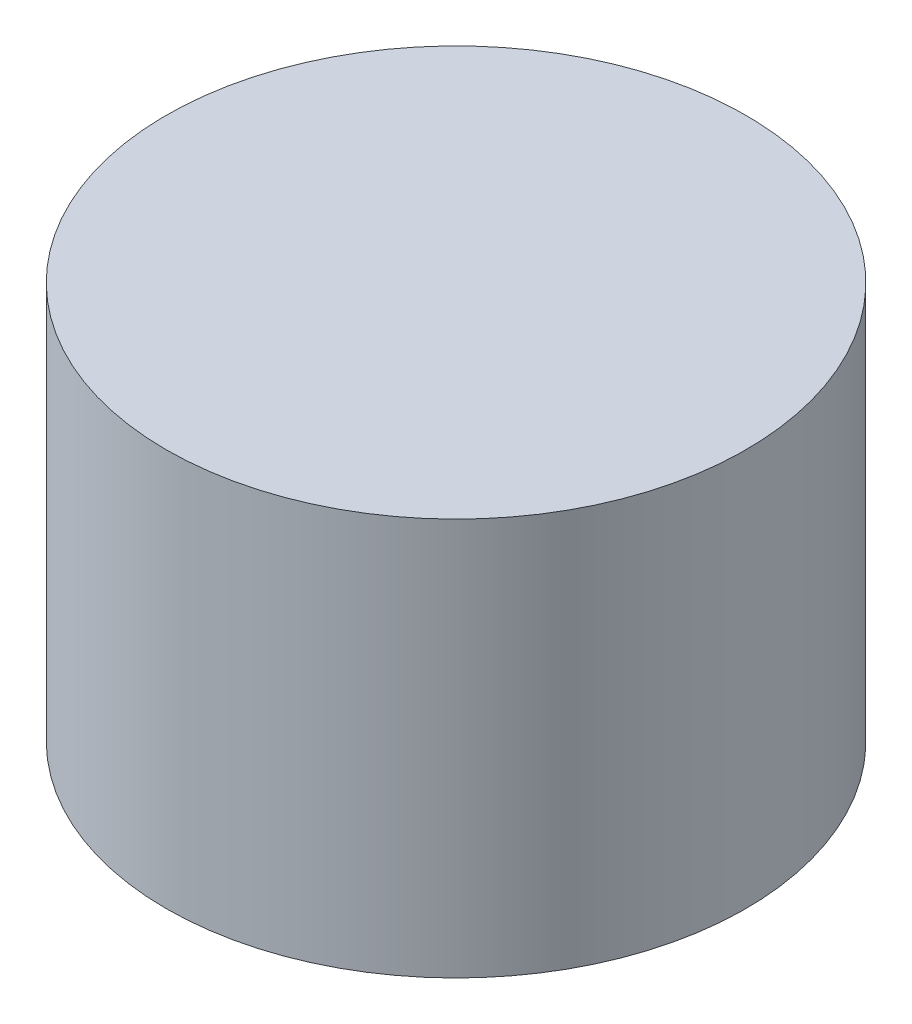
from build123d import *

# Parameters (mm, degrees)
SKETCH_1_R      = 52.5
EXTRUDE_1_DEPTH = 72


with BuildPart() as part:
    # 草图1 → 凸台-拉伸1 (new body)
    with BuildSketch(Plane(origin=(0, 0, 0), x_dir=(1, 0, 0), z_dir=(0, 1, 0))):
        Circle(SKETCH_1_R)
    extrude(amount=EXTRUDE_1_DEPTH)


solid = part.part
